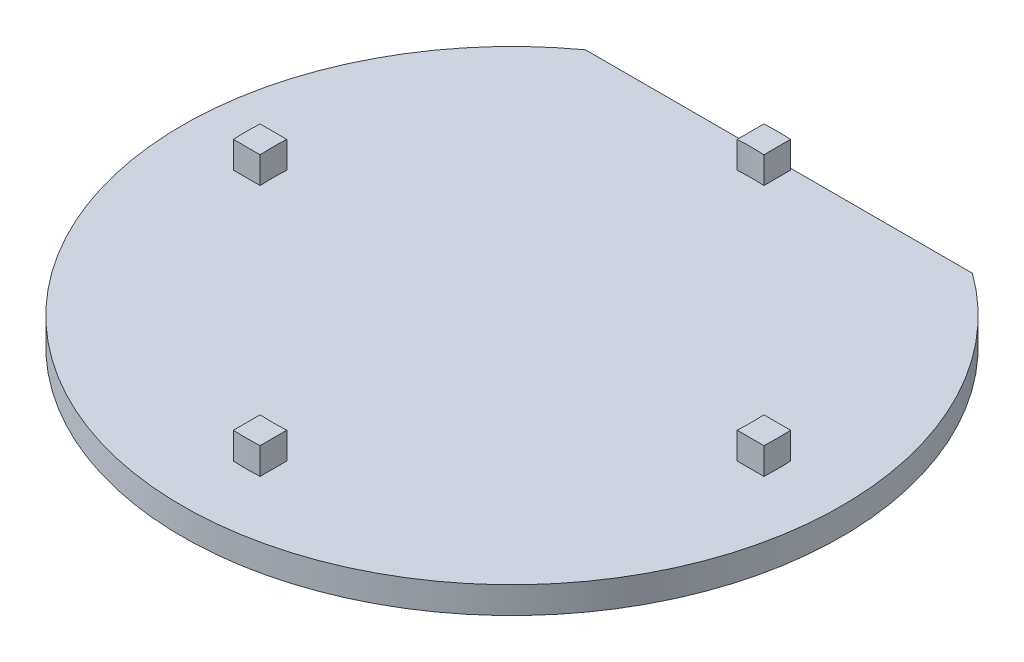
from build123d import *

# Parameters (mm, degrees)
BOSS_EXTRUDE1_DEPTH = 2
BOSS_EXTRUDE2_DEPTH = 2


with BuildPart() as part:
    # Sketch1 → Boss-Extrude1 (new body)
    with BuildSketch(Plane(origin=(0, 0, 0), x_dir=(1, 0, 0), z_dir=(0, 1, 0))):
        with BuildLine():
            Line((14.494481709, 20), (-14.494481709, 20))
            ThreePointArc((-14.494481709, 20), (0, -24.7), (14.494481709, 20))
        make_face()
    extrude(amount=BOSS_EXTRUDE1_DEPTH)

    # Sketch2 → Boss-Extrude2 (add)
    with BuildSketch(Plane(origin=(0, 2, 0), x_dir=(1, 0, 0), z_dir=(0, 1, 0))):
        with BuildLine():
            Line((1, 17.87204521), (1, 19.87485849))
            ThreePointArc((1, 19.87485849), (0, 19.9), (-1, 19.87485849))
            Line((-1, 19.87485849), (-1, 17.87204521))
            ThreePointArc((-1, 17.87204521), (0, 17.9), (1, 17.87204521))
        make_face()
        with BuildLine():
            Line((17.87204521, -1), (19.87485849, -1))
            ThreePointArc((19.87485849, -1), (19.9, 0), (19.87485849, 1))
            Line((19.87485849, 1), (17.87204521, 1))
            ThreePointArc((17.87204521, 1), (17.9, 0), (17.87204521, -1))
        make_face()
        with BuildLine():
            Line((-17.87204521, -1), (-19.87485849, -1))
            ThreePointArc((-19.87485849, -1), (-19.9, 0), (-19.87485849, 1))
            Line((-19.87485849, 1), (-17.87204521, 1))
            ThreePointArc((-17.87204521, 1), (-17.9, 0), (-17.87204521, -1))
        make_face()
        with BuildLine():
            Line((-1, -17.87204521), (-1, -19.87485849))
            ThreePointArc((-1, -19.87485849), (0, -19.9), (1, -19.87485849))
            Line((1, -19.87485849), (1, -17.87204521))
            ThreePointArc((1, -17.87204521), (0, -17.9), (-1, -17.87204521))
        make_face()
    extrude(amount=BOSS_EXTRUDE2_DEPTH)


solid = part.part
